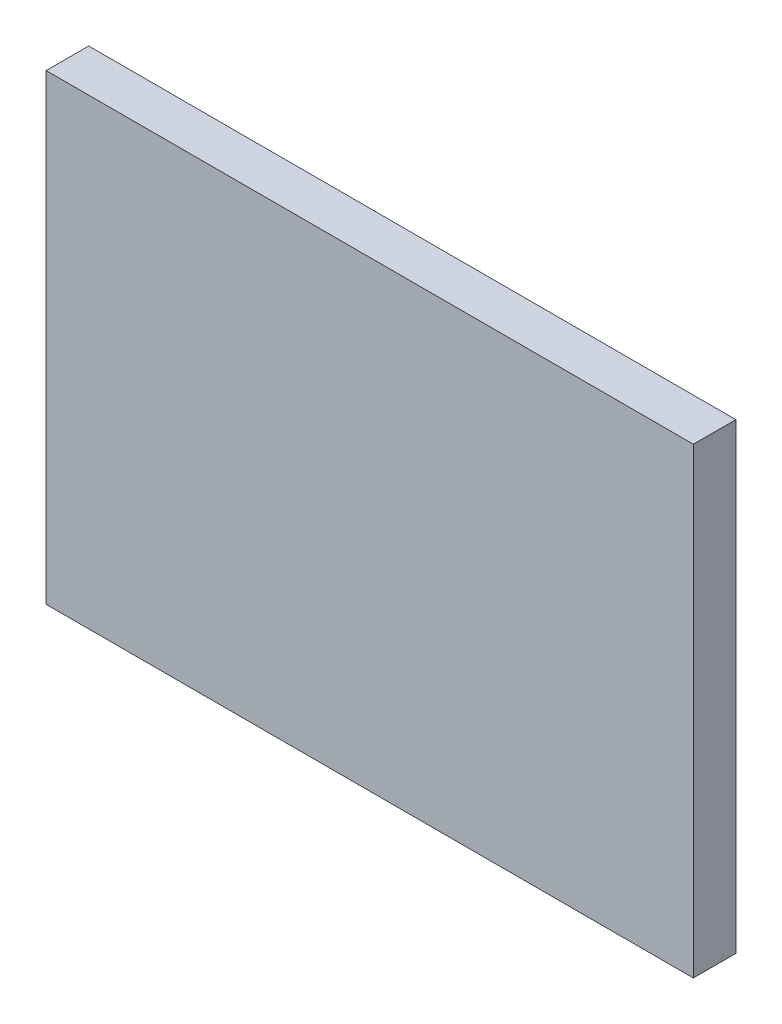
from build123d import *

# Parameters (mm, degrees)
SKETCH_1_W      = 35
SKETCH_1_H      = 25
EXTRUDE_1_DEPTH = 2.3


with BuildPart() as part:
    # 草图1 → 凸台-拉伸1 (new body)
    with BuildSketch(Plane.XY):
        with Locations((108.614983942, 61.563241835)):
            Rectangle(SKETCH_1_W, SKETCH_1_H)
    extrude(amount=EXTRUDE_1_DEPTH)


solid = part.part
